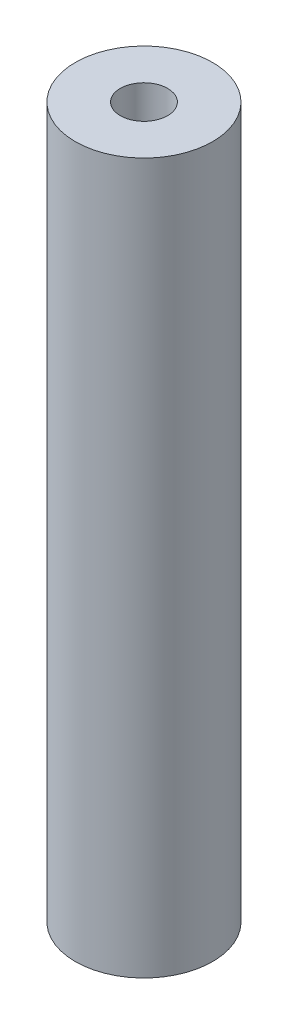
from build123d import *

# Parameters (mm, degrees)
SKETCH_1_R      = 2.9
SKETCH_1_R_2    = 1
EXTRUDE_1_DEPTH = 30


with BuildPart() as part:
    # 草图1 → 凸台-拉伸1 (new body)
    with BuildSketch(Plane(origin=(0, 0, 0), x_dir=(1, 0, 0), z_dir=(0, 1, 0))):
        with Locations((-1.479027352, 0.617821552)):
            Circle(SKETCH_1_R)
        with Locations((-1.479027352, 0.617821552)):
            Circle(SKETCH_1_R_2, mode=Mode.SUBTRACT)
    extrude(amount=EXTRUDE_1_DEPTH)


solid = part.part
